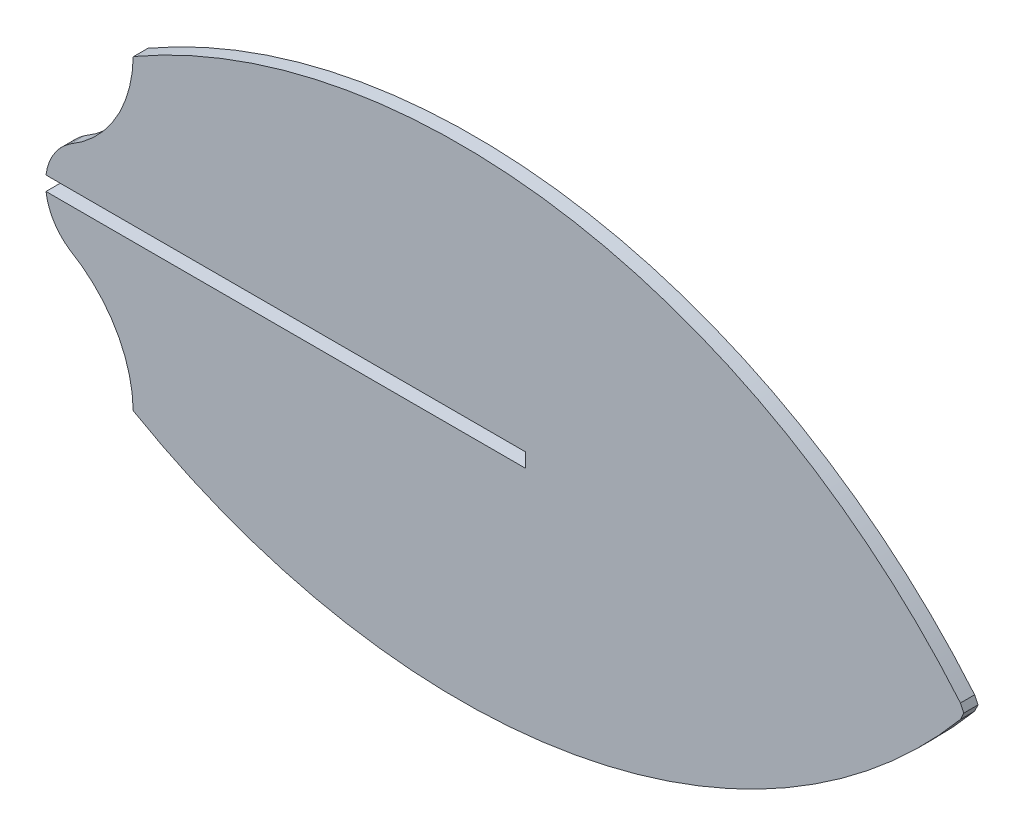
from build123d import *

# Parameters (mm, degrees)
BOSS_EXTRUDE1_DEPTH = 1.524


with BuildPart() as part:
    # Sketch1 → Boss-Extrude1 (new body)
    with BuildSketch(Plane.XY):
        with BuildLine():
            Line((79.357173925, 0), (79.357173925, -1.524))
            Line((79.357173925, -1.524), (27.997218561, -1.524))
            ThreePointArc((27.997218561, -1.524), (28.839303716, -3.893478834), (30.585272442, -5.703211014))
            ThreePointArc((30.585272442, -5.703211014), (35.473881568, -10.546204028), (37.343248984, -17.168782529))
            ThreePointArc((37.343248984, -17.168782529), (37.371863233, -17.198154529), (37.400490384, -17.227513955))
            ThreePointArc((37.400490384, -17.227513955), (84.54475886, -25.491518967), (125.974625666, -1.524))
            Line((125.974625666, -1.524), (126.331576391, -0.762))
            Line((126.331576391, -0.762), (125.974625666, 0))
            ThreePointArc((125.974625666, 0), (84.54475886, 23.967518967), (37.400490384, 15.703513955))
            ThreePointArc((37.400490384, 15.703513955), (37.371863233, 15.674154529), (37.343248984, 15.644782529))
            ThreePointArc((37.343248984, 15.644782529), (35.473881568, 9.022204028), (30.585272442, 4.179211014))
            ThreePointArc((30.585272442, 4.179211014), (28.839303716, 2.369478834), (27.997218561, 0))
            Line((27.997218561, 0), (79.357173925, 0))
        make_face()
    extrude(amount=BOSS_EXTRUDE1_DEPTH)


solid = part.part
